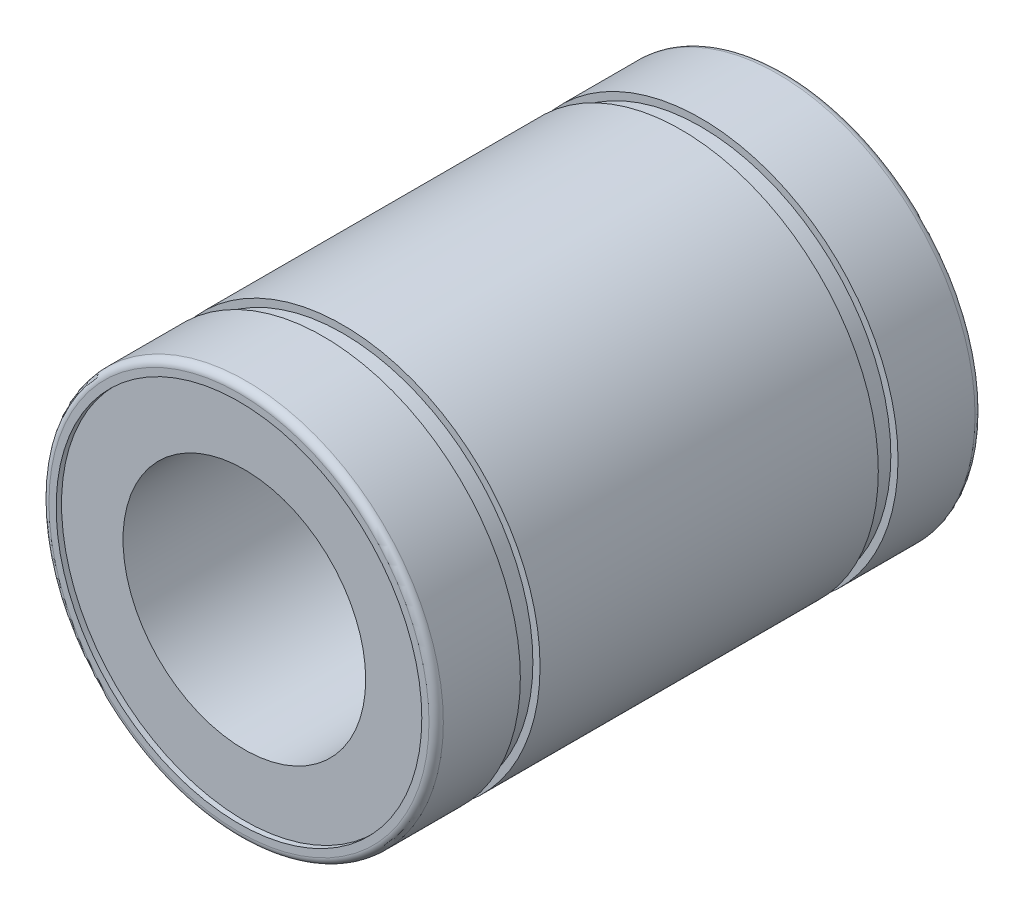
from build123d import *

# Parameters (mm, degrees)
SKETCH3_W = 1.3
SKETCH3_H = 0.473161305


with BuildPart() as part:
    # Sketch2 → Body (revolve)
    with BuildSketch(Plane(origin=(0, 0, 0), x_dir=(0, 0, -1), z_dir=(1, 0, 0))):
        with BuildLine():
            Line((-17.645349183, 12.053677391), (-18, 12.053677391))
            Line((-18, 12.053677391), (-18, 12.526838695))
            ThreePointArc((-18, 12.526838695), (-17.861414262, 12.861414262), (-17.526838695, 13))
            Line((-17.526838695, 13), (17.526838695, 13))
            ThreePointArc((17.526838695, 13), (17.861414262, 12.861414262), (18, 12.526838695))
            Line((18, 12.526838695), (18, 12.053677391))
            Line((18, 12.053677391), (17.645349183, 12.053677391))
            Line((17.645349183, 12.053677391), (17.645349183, 8))
            Line((17.645349183, 8), (-17.645349183, 8))
            Line((-17.645349183, 8), (-17.645349183, 12.053677391))
        make_face()
    revolve(axis=Axis((0, 0, 18), (0, 0, -1)))

    # Sketch3 → Track (revolve, cut)
    with BuildSketch(Plane(origin=(0, 0, 0), x_dir=(0, 0, -1), z_dir=(1, 0, 0))):
        with Locations((11.8, 12.763419348)):
            Rectangle(SKETCH3_W, SKETCH3_H)
        with Locations((-11.8, 12.763419348)):
            Rectangle(SKETCH3_W, SKETCH3_H)
    revolve(axis=Axis((0, 0, 18), (0, 0, -1)), mode=Mode.SUBTRACT)


solid = part.part
